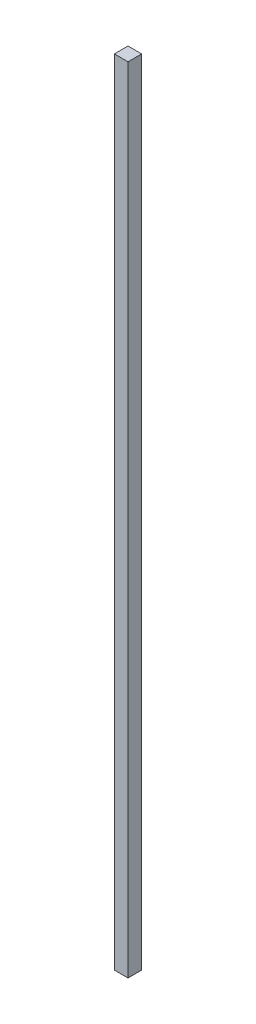
from build123d import *

# Parameters (mm, degrees)
SKETCH1_W           = 25.4
SKETCH1_H           = 25.4
BOSS_EXTRUDE1_DEPTH = 1473.2


with BuildPart() as part:
    # Sketch1 → Boss-Extrude1 (new body)
    with BuildSketch(Plane(origin=(0, 0, 0), x_dir=(1, 0, 0), z_dir=(0, 1, 0))):
        with Locations((12.7, 12.7)):
            Rectangle(SKETCH1_W, SKETCH1_H)
    extrude(amount=BOSS_EXTRUDE1_DEPTH)


solid = part.part
